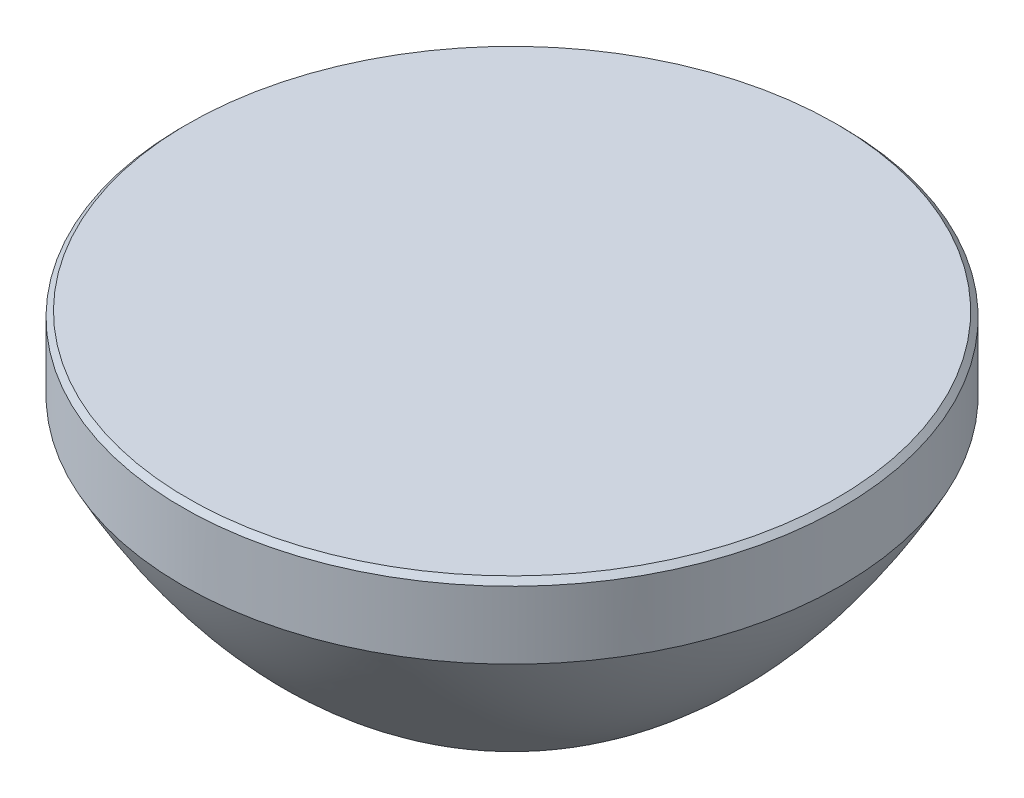
from build123d import *


with BuildPart() as part:
    # Sketch1 → Revolve1 (revolve)
    with BuildSketch(Plane.XY):
        with BuildLine():
            Line((12.3, 6), (0, 6))
            Line((0, 6), (0, -6))
            add(Edge.make_bspline(
                [(0, -6), (7.572028357, -5.970173128), (12.5, 3.239347004)],
                knots=[3.082837396, 3.082837396, 3.082837396, 3.808197619, 3.808197619, 3.808197619], degree=2, weights=[1, 0.934949329, 1]))
            Line((12.5, 3.239347004), (12.5, 5.8))
            Line((12.5, 5.8), (12.3, 6))
        make_face()
    revolve(axis=Axis((0, 6, 0), (0, -1, 0)))


solid = part.part
